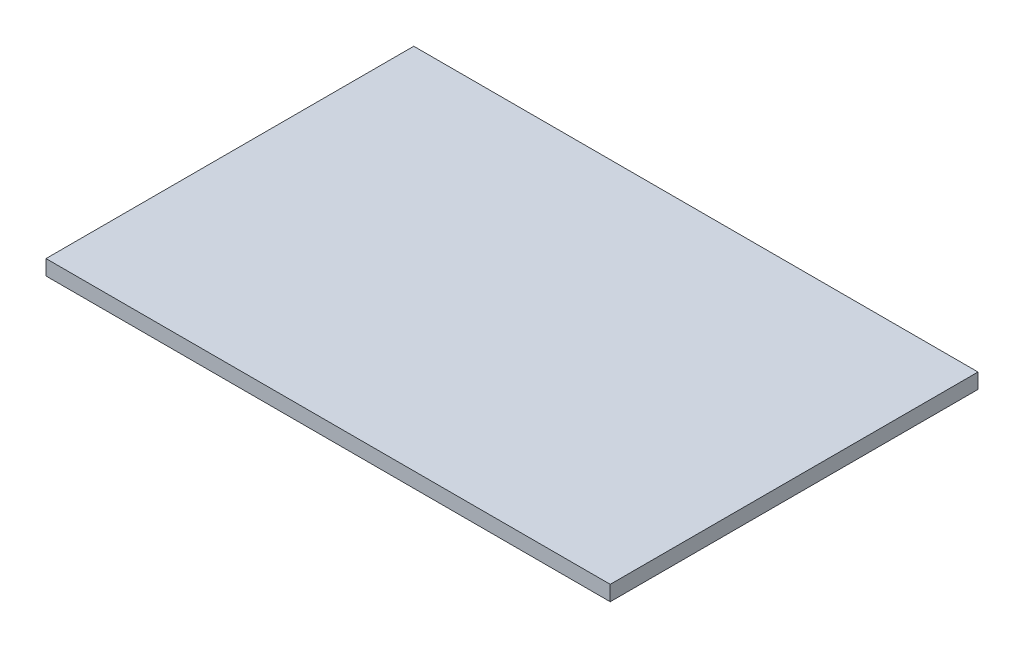
from build123d import *

# Parameters (mm, degrees)
SKETCH1_W           = 112
SKETCH1_H           = 73
BOSS_EXTRUDE1_DEPTH = 3


with BuildPart() as part:
    # Sketch1 → Boss-Extrude1 (new body)
    with BuildSketch(Plane(origin=(0, 0, 0), x_dir=(1, 0, 0), z_dir=(0, 1, 0))):
        Rectangle(SKETCH1_W, SKETCH1_H)
    extrude(amount=BOSS_EXTRUDE1_DEPTH)


solid = part.part
